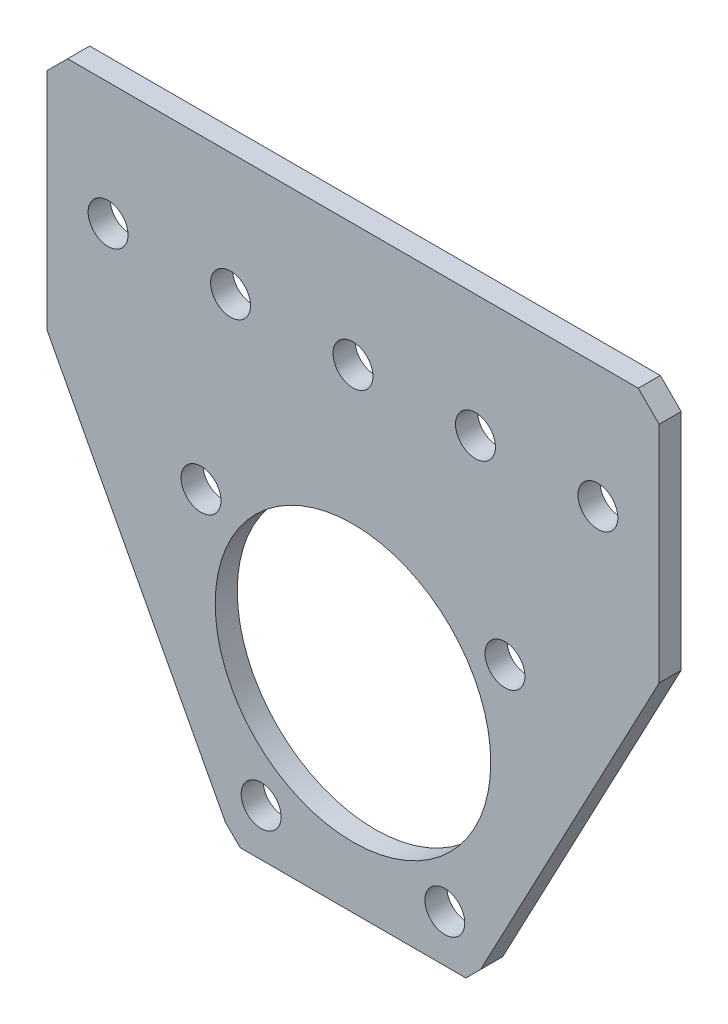
from build123d import *

# Parameters (mm, degrees)
SKETCH1_R           = 2.0701
SKETCH1_R_2         = 14.2875
BOSS_EXTRUDE1_DEPTH = 2.286


with BuildPart() as part:
    # Sketch1 → Boss-Extrude1 (new body)
    with BuildSketch(Plane(origin=(0, 0, 0), x_dir=(-1, 0, 0), z_dir=(0, 0, -1))):
        Polygon((-29.591, 41.275), (-31.75, 39.116), (-31.75, 15.875), (-13.235753401, -19.110856459), (-11.70910986, -20.6375), (11.70910986, -20.6375), (13.235753401, -19.110856459), (31.75, 15.875), (31.75, 39.116), (29.591, 41.275), align=None)
        with Locations((-15.76028553, 9.525)):
            Circle(SKETCH1_R, mode=Mode.SUBTRACT)
        with Locations((9.525, -15.76028553)):
            Circle(SKETCH1_R, mode=Mode.SUBTRACT)
        with Locations((-12.7, 28.575)):
            Circle(SKETCH1_R, mode=Mode.SUBTRACT)
        with Locations((12.7, 28.575)):
            Circle(SKETCH1_R, mode=Mode.SUBTRACT)
        with Locations((25.4, 28.575)):
            Circle(SKETCH1_R, mode=Mode.SUBTRACT)
        Circle(SKETCH1_R_2, mode=Mode.SUBTRACT)
        with Locations((-25.4, 28.575)):
            Circle(SKETCH1_R, mode=Mode.SUBTRACT)
        with Locations((0, 28.575)):
            Circle(SKETCH1_R, mode=Mode.SUBTRACT)
        with Locations((15.76028553, 9.525)):
            Circle(SKETCH1_R, mode=Mode.SUBTRACT)
        with Locations((-9.525, -15.76028553)):
            Circle(SKETCH1_R, mode=Mode.SUBTRACT)
    extrude(amount=-BOSS_EXTRUDE1_DEPTH)


solid = part.part
